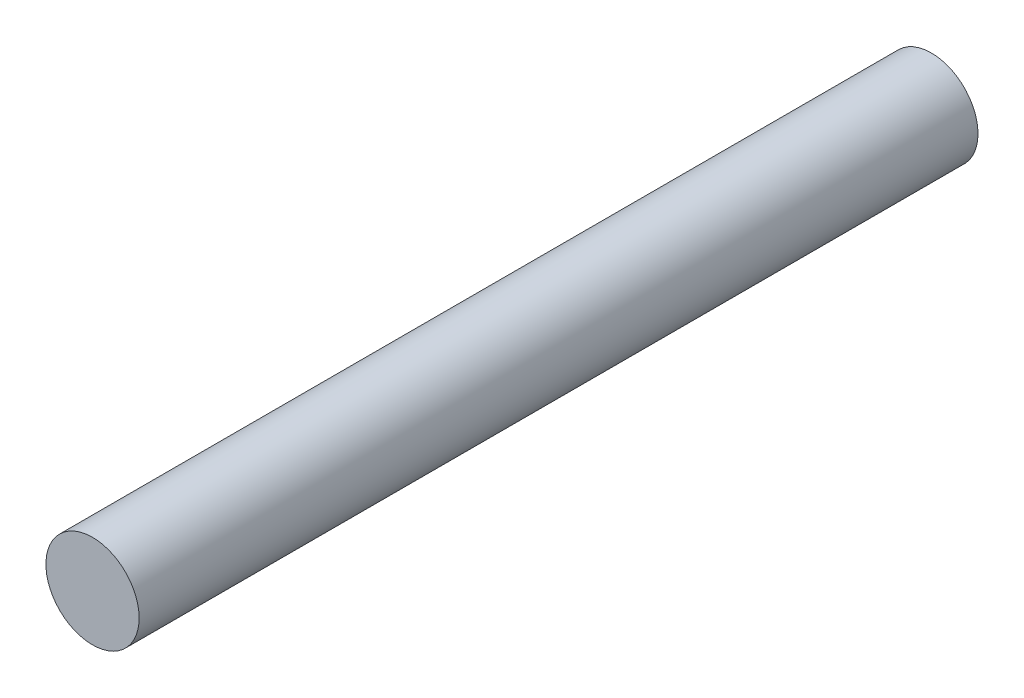
from build123d import *

# Parameters (mm, degrees)
SKETCH1_R           = 4
BOSS_EXTRUDE1_DEPTH = 72


with BuildPart() as part:
    # Sketch1 → Boss-Extrude1 (new body)
    with BuildSketch(Plane.XY):
        Circle(SKETCH1_R)
    extrude(amount=BOSS_EXTRUDE1_DEPTH)


solid = part.part
